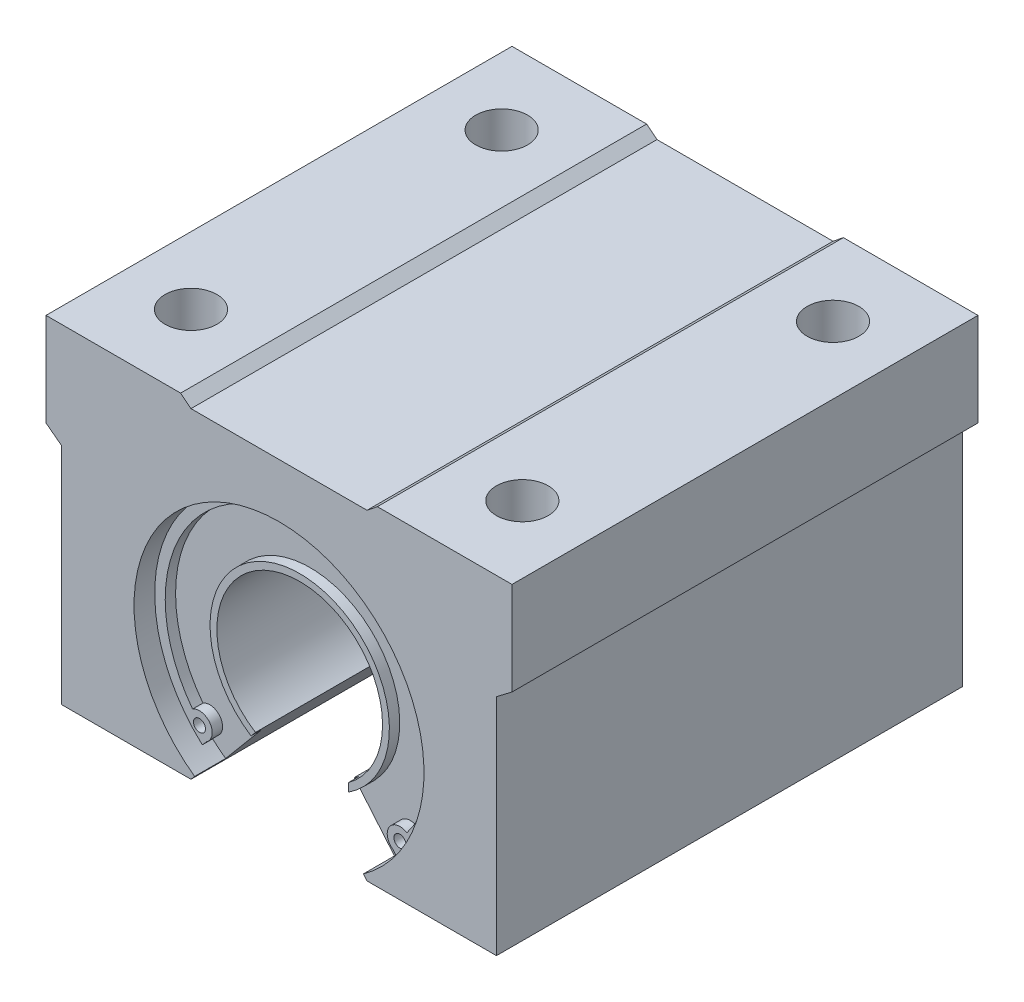
from build123d import *

# Parameters (mm, degrees)
RESSALTO_EXTRUS_O1_DEPTH = 45
ESBO_O3_R                = 14
CORTE_EXTRUS_O2_DEPTH    = 3
ESBO_O4_R                = 8.659932388
ESBO_O4_R_2              = 8
RESSALTO_EXTRUS_O2_DEPTH = 1
CORTE_EXTRUS_O3_DEPTH    = 1
ESBO_O6_R                = 0.581806569
RESSALTO_EXTRUS_O3_DEPTH = 1
ESBO_O8_W                = 66.682798833
ESBO_O8_H                = 46.433556561
CORTE_EXTRUS_O5_DEPTH    = 23.5
ESBO_O9_R                = 2.5
CORTE_EXTRUS_O6_DEPTH    = 14


with BuildPart() as part:
    # Esboço1 → Ressalto-extrusão1 (new body)
    with BuildSketch(Plane.XY):
        with BuildLine():
            Line((-22.5, 20), (-22.5, 11))
            Line((-22.5, 11), (-21, 9.864062641))
            Line((-21, 9.864062641), (-21, -11.8))
            Line((-21, -11.8), (-8.5, -11.8))
            Line((-8.5, -11.8), (-4.27343132, -6.762971592))
            ThreePointArc((-4.27343132, -6.762971592), (0, 8), (4.27343132, -6.762971592))
            Line((4.27343132, -6.762971592), (8.5, -11.8))
            Line((8.5, -11.8), (21, -11.8))
            Line((21, -11.8), (21, 9.864062641))
            Line((21, 9.864062641), (22.5, 11))
            Line((22.5, 11), (22.5, 20))
            Line((22.5, 20), (9.5, 20))
            Line((9.5, 20), (8.5, 19.2))
            Line((8.5, 19.2), (-8.5, 19.2))
            Line((-8.5, 19.2), (-9.5, 20))
            Line((-9.5, 20), (-22.5, 20))
        make_face()
    extrude(amount=RESSALTO_EXTRUS_O1_DEPTH)

    # Esboço3 → Corte-extrusão2 (cut)
    with BuildSketch(Plane(origin=(0, 0, 0), x_dir=(-1, 0, 0), z_dir=(0, 0, -1))):
        Circle(ESBO_O3_R)
    extrude(amount=-CORTE_EXTRUS_O2_DEPTH, mode=Mode.SUBTRACT)

    # Esboço4 → Ressalto-extrusão2 (add)
    with BuildSketch(Plane(origin=(0, 0, 3), x_dir=(-1, 0, 0), z_dir=(0, 0, -1))):
        Circle(ESBO_O4_R)
        Circle(ESBO_O4_R_2, mode=Mode.SUBTRACT)
    extrude(amount=RESSALTO_EXTRUS_O2_DEPTH)

    # Esboço5 → Corte-extrusão3 (cut)
    with BuildSketch(Plane(origin=(0, 0, 3), x_dir=(-1, 0, 0), z_dir=(0, 0, -1))):
        Polygon((-8.150170401, -11.383089319), (-4.701200585, -7.27276715), (-4.703249192, -5.654958468), (3.343697917, -5.654958468), (4.701200585, -7.27276715), (8.150170401, -11.383089319), (0.388307104, -10.144815057), align=None)
    extrude(amount=CORTE_EXTRUS_O3_DEPTH, mode=Mode.SUBTRACT)

    # Esboço6 → Ressalto-extrusão3 (add)
    with BuildSketch(Plane(origin=(0, 0, 3), x_dir=(-1, 0, 0), z_dir=(0, 0, -1))):
        with BuildLine():
            Line((-8.96541648, -9.883119832), (-9.879437481, -10.890700362))
            ThreePointArc((-9.879437481, -10.890700362), (0, 14.704102805), (9.879437481, -10.890700362))
            Line((9.879437481, -10.890700362), (8.96541648, -9.883119832))
            ThreePointArc((8.96541648, -9.883119832), (8.661852403, -8.191590578), (10.346023957, -7.849554692))
            ThreePointArc((10.346023957, -7.849554692), (0, 12.986751733), (-10.346023957, -7.849554692))
            ThreePointArc((-10.346023957, -7.849554692), (-8.661852403, -8.191590578), (-8.96541648, -9.883119832))
        make_face()
        with Locations((-9.678899136, -8.882073659)):
            Circle(ESBO_O6_R, mode=Mode.SUBTRACT)
        with Locations((9.678899136, -8.882073659)):
            Circle(ESBO_O6_R, mode=Mode.SUBTRACT)
    extrude(amount=RESSALTO_EXTRUS_O3_DEPTH)

    # Esboço8 → Corte-extrusão5 (cut, through all)
    with BuildSketch(Plane.XY.offset(22.5)):
        with Locations((0.496680915, 3.185740871)):
            Rectangle(ESBO_O8_W, ESBO_O8_H)
    extrude(amount=CORTE_EXTRUS_O5_DEPTH, mode=Mode.SUBTRACT)

    # Espelhar14: part across plane


with BuildPart() as part_1:
    add(part.part)
    add(part.part.mirror(Plane.XY.offset(22.5)))

    # Esboço9 → Corte-extrusão6 (cut)
    with BuildSketch(Plane(origin=(0, 20, 0), x_dir=(1, 0, 0), z_dir=(0, 1, 0))):
        with Locations((-16, -7.5)):
            Circle(ESBO_O9_R)
        with Locations((16, -7.5)):
            Circle(ESBO_O9_R)
        with Locations((16, -37.5)):
            Circle(ESBO_O9_R)
        with Locations((-16, -37.5)):
            Circle(ESBO_O9_R)
    extrude(amount=-CORTE_EXTRUS_O6_DEPTH, mode=Mode.SUBTRACT)


solid = part_1.part
